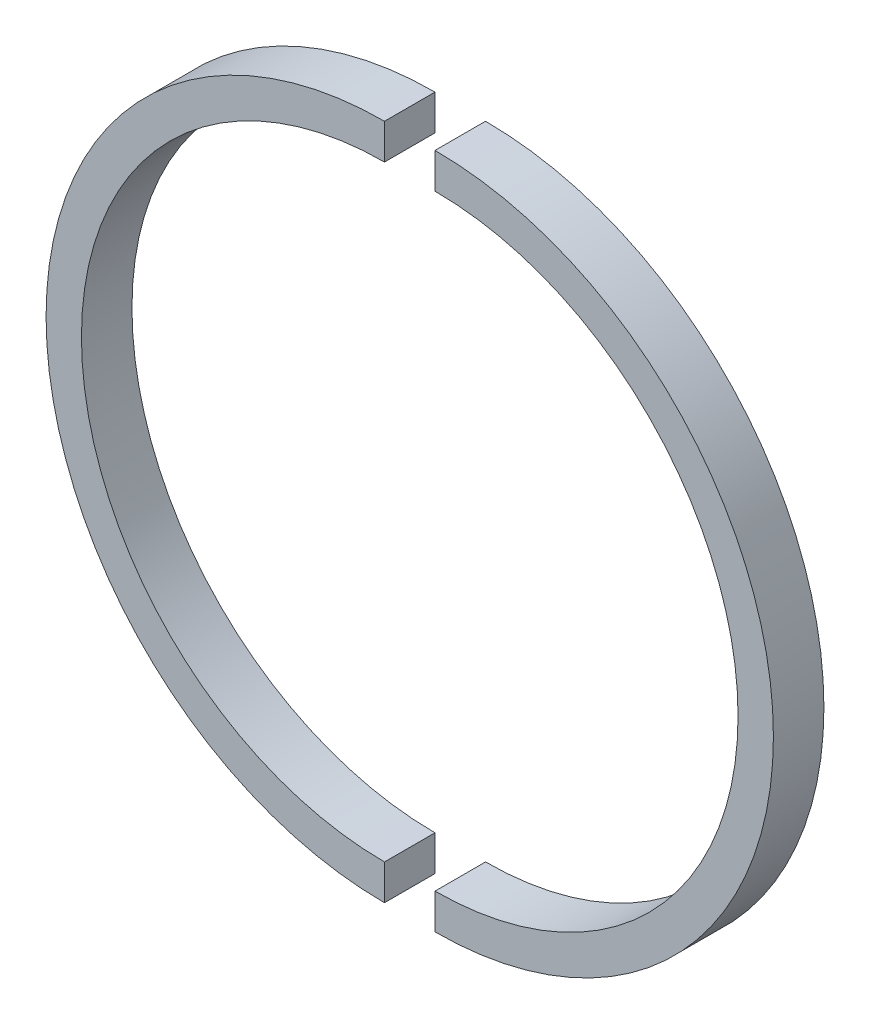
from build123d import *

# Parameters (mm, degrees)
SKETCH1_W      = 10
SKETCH1_H      = 7
REVOLVE1_ANGLE = 180
SKETCH4_W      = 10
SKETCH4_H      = 7
REVOLVE3_ANGLE = 180


with BuildPart() as part:
    # Sketch1 → Revolve1 (revolve)
    with BuildSketch(Plane(origin=(0, 0, 0), x_dir=(0, 0, -1), z_dir=(1, 0, 0))):
        with Locations((0, 63.5)):
            Rectangle(SKETCH1_W, SKETCH1_H)
    revolve(axis=Axis((0, 0, 29.874383247), (0, 0, 1)), revolution_arc=REVOLVE1_ANGLE)


with BuildPart() as body_2:
    # Sketch4 → Revolve3 (revolve)
    with BuildSketch(Plane(origin=(10, 0, 0), x_dir=(0, 0, -1), z_dir=(1, 0, 0))):
        with Locations((0, 63.5)):
            Rectangle(SKETCH4_W, SKETCH4_H)
    revolve(axis=Axis((10, 0, 23.347655249), (0, 0, -1)), revolution_arc=REVOLVE3_ANGLE)


solid = Compound([part.part, body_2.part])
